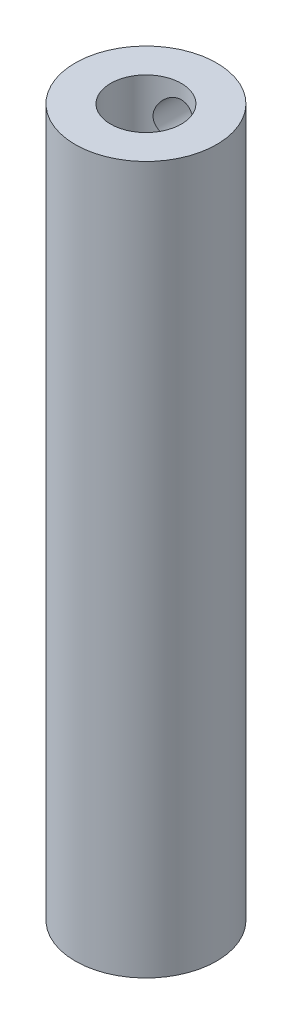
from build123d import *

# Parameters (mm, degrees)
SKETCH1_R           = 10
BOSS_EXTRUDE1_DEPTH = 100
SKETCH2_R           = 5
CUT_EXTRUDE1_DEPTH  = 20
SKETCH3_R           = 3
CUT_EXTRUDE2_DEPTH  = 18


with BuildPart() as part:
    # Sketch1 → Boss-Extrude1 (new body)
    with BuildSketch(Plane(origin=(0, 0, 0), x_dir=(1, 0, 0), z_dir=(0, 1, 0))):
        Circle(SKETCH1_R)
    extrude(amount=BOSS_EXTRUDE1_DEPTH)

    # Sketch2 → Cut-Extrude1 (cut)
    with BuildSketch(Plane(origin=(0, 100, 0), x_dir=(1, 0, 0), z_dir=(0, 1, 0))):
        Circle(SKETCH2_R)
    extrude(amount=-CUT_EXTRUDE1_DEPTH, mode=Mode.SUBTRACT)

    # Sketch3 → Cut-Extrude2 (cut)
    with BuildSketch(Plane.XY):
        with Locations((0, 95)):
            Circle(SKETCH3_R)
    extrude(amount=-CUT_EXTRUDE2_DEPTH, mode=Mode.SUBTRACT)


solid = part.part
